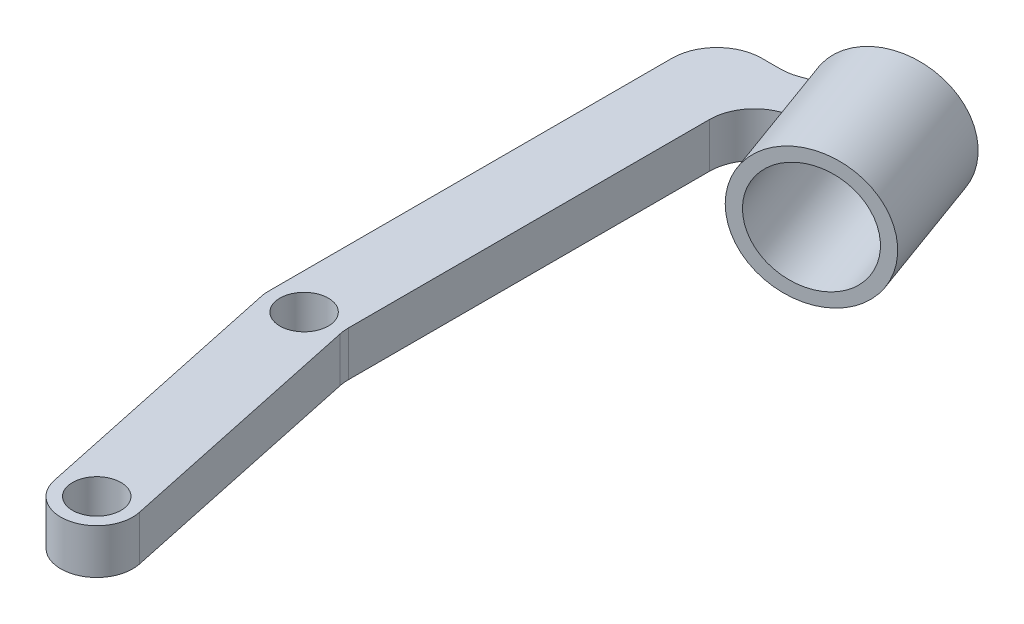
from build123d import *

# Parameters (mm, degrees)
SKETCH1_R           = 2.7
BOSS_EXTRUDE2_DEPTH = 5
FILLET2_R           = 5
SKETCH2_R           = 7.5
SKETCH2_R_2         = 6
BOSS_EXTRUDE3_DEPTH = 15
CUT_EXTRUDE1_DEPTH  = 15


with BuildPart() as part:
    # Sketch1 → Boss-Extrude2 (new body)
    with BuildSketch(Plane(origin=(0, 0, 0), x_dir=(1, 0, 0), z_dir=(0, 1, 0))):
        with BuildLine():
            Line((-10.149941127, 28.512781259), (-3.912590403, -0.831646763))
            ThreePointArc((-3.912590403, -0.831646763), (0.831646763, -3.912590403), (3.912590403, 0.831646763))
            Line((3.912590403, 0.831646763), (-2.237350725, 29.764844963))
            Line((-2.237350725, 29.764844963), (-2.237350725, 74.02353916))
            Line((-2.237350725, 74.02353916), (13.568139304, 79.776267068))
            Line((13.568139304, 79.776267068), (11.858038587, 84.474730172))
            Line((11.858038587, 84.474730172), (-2.237350725, 79.344428022))
            Line((-2.237350725, 79.344428022), (-10.237350725, 79.344428022))
            Line((-10.237350725, 79.344428022), (-10.237350725, 29.344428022))
            ThreePointArc((-10.237350725, 29.344428022), (-10.215438306, 28.926314169), (-10.149941127, 28.512781259))
        make_face()
        with Locations((-6.237350725, 29.344428022)):
            Circle(SKETCH1_R, mode=Mode.SUBTRACT)
        Circle(SKETCH1_R, mode=Mode.SUBTRACT)
    extrude(amount=BOSS_EXTRUDE2_DEPTH)

    # Fillet2
    fillet2_edges = [part.edges().sort_by_distance(p)[0] for p in [
        (-2.237350725, 2.5, -79.344428022),
        (-10.237350725, 2.5, -79.344428022),
        (-2.237350725, 2.5, -74.02353916),
        (-2.237350725, 2.5, -29.764844963),
    ]]
    fillet(fillet2_edges, radius=FILLET2_R)

    # Sketch2 → Boss-Extrude3 (add)
    with BuildSketch(Plane(origin=(-25.762527932, 0, -70.781963762), x_dir=(-0.9396926207859105, 0, 0.3420201433256629), z_dir=(-0.34202014332566294, 0, -0.9396926207859106))):
        with Locations((-34.010040431, 2.5)):
            Circle(SKETCH2_R)
        with Locations((-34.010040431, 2.5)):
            Circle(SKETCH2_R_2, mode=Mode.SUBTRACT)
    extrude(amount=-BOSS_EXTRUDE3_DEPTH)

    # Sketch2_2 → Cut-Extrude1 (cut)
    with BuildSketch(Plane(origin=(-25.762527932, 0, -70.781963762), x_dir=(-0.9396926207859105, 0, 0.3420201433256629), z_dir=(-0.34202014332566294, 0, -0.9396926207859106))):
        with BuildLine():
            ThreePointArc((-28.010040431, 2.5), (-28.148038369, 3.779426367), (-28.555684374, 5))
            Line((-28.555684374, 5), (-39.464396489, 5))
            ThreePointArc((-39.464396489, 5), (-40.010040431, 2.5), (-39.464396489, 0))
            Line((-39.464396489, 0), (-28.555684374, 0))
            ThreePointArc((-28.555684374, 0), (-28.148038369, 1.220573633), (-28.010040431, 2.5))
        make_face()
    extrude(amount=-CUT_EXTRUDE1_DEPTH, mode=Mode.SUBTRACT)


solid = part.part
